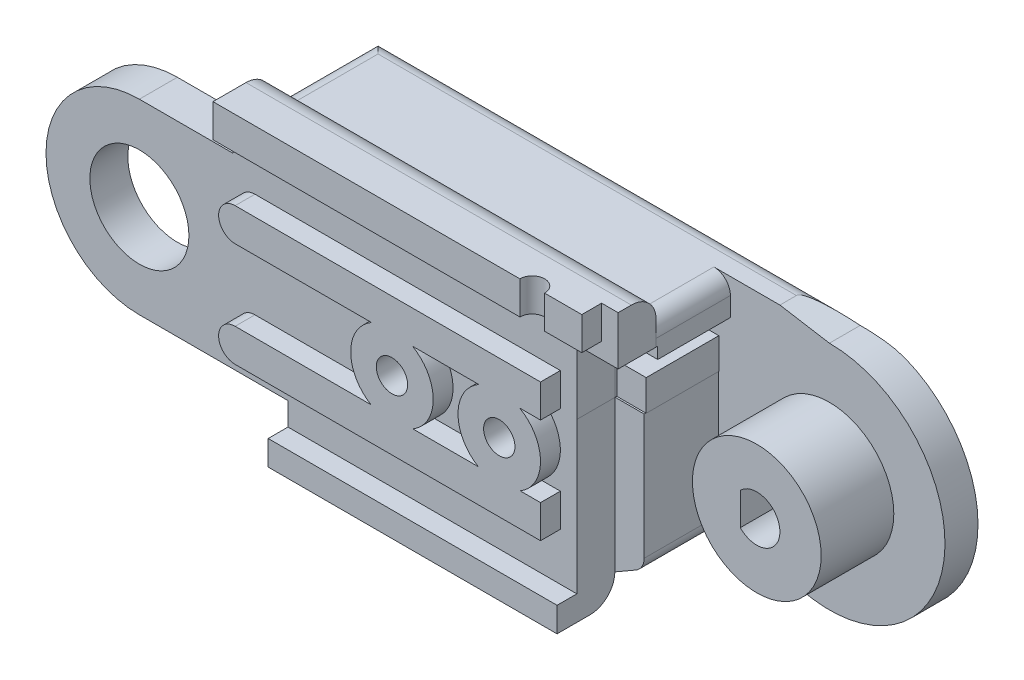
from build123d import *

# Parameters (mm, degrees)
BOSS_EXTRUDE1_DEPTH  = 2
BOSS_EXTRUDE6_DEPTH  = 4.5
CUT_EXTRUDE6_DEPTH   = 4.5
BOSS_EXTRUDE14_DEPTH = 2.3
SKETCH32_R           = 3
CUT_EXTRUDE7_DEPTH   = 2.3
SKETCH33_W           = 22.343119157
SKETCH33_H           = 2
SKETCH33_W_2         = 17.499973406
SKETCH33_H_2         = 1.5
BOSS_EXTRUDE15_DEPTH = 1.2
SKETCH35_W           = 5.479645996
SKETCH35_H           = 3.871139505
CUT_EXTRUDE8_DEPTH   = 2.4
SKETCH36_W           = 3.7
SKETCH36_H           = 1.871139505
CUT_EXTRUDE9_DEPTH   = 4.4
SKETCH37_R           = 3.9
BOSS_EXTRUDE16_DEPTH = 4.4
CUT_EXTRUDE10_DEPTH  = 7.4
SKETCH43_R           = 2.5
BOSS_EXTRUDE17_DEPTH = 1.2
SKETCH44_R           = 0.95
CUT_EXTRUDE11_DEPTH  = 11
SKETCH45_R           = 2
CUT_EXTRUDE12_DEPTH  = 4.5
SKETCH49_R           = 0.75
CUT_EXTRUDE13_DEPTH  = 3
SKETCH51_W           = 3
SKETCH51_H           = 3.965585241
CUT_EXTRUDE14_DEPTH  = 6.8
FILLET1_R            = 1.5
FILLET3_R            = 1


with BuildPart() as part:
    # Sketch3 → Boss-Extrude1 (new body)
    with BuildSketch(Plane.XY):
        with BuildLine():
            Line((8, 0), (9, -2.543145751))
            Line((9, -2.543145751), (9, -7.043145751))
            Line((9, -7.043145751), (26.499973406, -7.043145751))
            Line((26.499973406, -7.043145751), (30.050225938, -4.992893219))
            ThreePointArc((30.050225938, -4.992893219), (41.467130134, -2.721929777), (34.999973406, 6.956854249))
            Line((34.999973406, 6.956854249), (31.999973406, 7.456854249))
            Line((31.999973406, 7.456854249), (5.656854249, 7.456854249))
            Line((5.656854249, 7.456854249), (5.656854249, 5.656854249))
            ThreePointArc((5.656854249, 5.656854249), (7.39103626, 3.061467459), (8, 0))
        make_face()
    extrude(amount=BOSS_EXTRUDE1_DEPTH)

    # Sketch22 → Boss-Extrude6 (add)
    with BuildSketch(Plane.XY.offset(2)):
        with BuildLine():
            Line((5.656854249, 7.456854249), (26.499973406, 7.456854249))
            Line((26.499973406, 7.456854249), (31.999973406, 7.456854249))
            Line((31.999973406, 7.456854249), (31.999973406, 2.128860495))
            Line((31.999973406, 2.128860495), (28.275099672, 2.128860495))
            Line((28.275099672, 2.128860495), (28.275099672, -6.018019485))
            Line((28.275099672, -6.018019485), (26.499973406, -7.043145751))
            Line((26.499973406, -7.043145751), (9, -7.043145751))
            Line((9, -7.043145751), (9, -2.543145751))
            Line((9, -2.543145751), (8, 0))
            ThreePointArc((8, 0), (7.39103626, 3.061467459), (5.656854249, 5.656854249))
            Line((5.656854249, 5.656854249), (5.656854249, 7.456854249))
        make_face()
    extrude(amount=BOSS_EXTRUDE6_DEPTH)

    # Sketch26 → Cut-Extrude6 (cut)
    with BuildSketch(Plane.XY.offset(2)):
        Polygon((18.098080448, 5.3), (2.530052458, 5.3), (2.530052458, 4), (18.098080448, 4), (31.999973406, 4), (31.999973406, 5.3), align=None)
    extrude(amount=CUT_EXTRUDE6_DEPTH, mode=Mode.SUBTRACT)


with BuildPart() as body_2:
    # Sketch31 → Boss-Extrude14 (new body)
    with BuildSketch(Plane.XY.offset(6.5)):
        with BuildLine():
            Line((2.432688066, 5.656854249), (0, 5.656854249))
            ThreePointArc((0, 5.656854249), (-5.656854249, 0), (0, -5.656854249))
            Line((0, -5.656854249), (9, -5.656854249))
            Line((9, -5.656854249), (9, -7.043145751))
            Line((9, -7.043145751), (9, -8.543145751))
            Line((9, -8.543145751), (26.499973406, -8.543145751))
            Line((26.499973406, -8.543145751), (26.499973406, -7.043145751))
            Line((26.499973406, -7.043145751), (26.499973406, 2.128860495))
            Line((26.499973406, 2.128860495), (28.275099672, 2.128860495))
            Line((28.275099672, 2.128860495), (31.999973406, 2.128860495))
            Line((31.999973406, 2.128860495), (31.999973406, 7.456854249))
            Line((31.999973406, 7.456854249), (31.999973406, 8.956854249))
            Line((31.999973406, 8.956854249), (5.656854249, 8.956854249))
            Line((5.656854249, 8.956854249), (5.656854249, 7.456854249))
            Line((5.656854249, 7.456854249), (5.656854249, 5.656854249))
            Line((5.656854249, 5.656854249), (2.432688066, 5.656854249))
        make_face()
    extrude(amount=BOSS_EXTRUDE14_DEPTH)

    # Sketch32 → Cut-Extrude7 (cut)
    with BuildSketch(Plane.XY.offset(8.8)):
        Circle(SKETCH32_R)
    extrude(amount=-CUT_EXTRUDE7_DEPTH, mode=Mode.SUBTRACT)

    # Sketch33 → Boss-Extrude15 (add)
    with BuildSketch(Plane.XY.offset(8.8)):
        with Locations((16.828413828, 7.956854249)):
            Rectangle(SKETCH33_W, SKETCH33_H)
        with Locations((17.749986703, -7.793145751)):
            Rectangle(SKETCH33_W_2, SKETCH33_H_2)
        with BuildLine():
            Line((7, -4.156854249), (25.499973406, -4.156854249))
            Line((25.499973406, -4.156854249), (25.499973406, -2.156854249))
            Line((25.499973406, -2.156854249), (7, -2.156854249))
            ThreePointArc((7, -2.156854249), (6, -3.156854249), (7, -4.156854249))
        make_face()
        with BuildLine():
            Line((25.499973406, 2.172006245), (7, 2.172006245))
            ThreePointArc((7, 2.172006245), (6, 3.172006245), (7, 4.172006245))
            Line((7, 4.172006245), (25.499973406, 4.172006245))
            Line((25.499973406, 4.172006245), (25.499973406, 2.172006245))
        make_face()
    extrude(amount=BOSS_EXTRUDE15_DEPTH)


with BuildPart() as cut_extrude8_tool:
    # Sketch35 → Cut-Extrude8 (new body)
    with BuildSketch(Plane.XY.offset(8.8)):
        with Locations((29.260150408, 4.064430247)):
            Rectangle(SKETCH35_W, SKETCH35_H)
    extrude(amount=-CUT_EXTRUDE8_DEPTH)


with BuildPart() as part_1:
    add(part.part)

    # Cut-Extrude8: cut by cut_extrude8_tool
    add(cut_extrude8_tool.part, mode=Mode.SUBTRACT)

    # Sketch36 → Cut-Extrude9 (cut)
    with BuildSketch(Plane.XY.offset(6.4)):
        with Locations((30.149973406, 3.064430247)):
            Rectangle(SKETCH36_W, SKETCH36_H)
    extrude(amount=-CUT_EXTRUDE9_DEPTH, mode=Mode.SUBTRACT)

    # Sketch37 → Boss-Extrude16 (add)
    with BuildSketch(Plane.XY.offset(2)):
        with Locations((34.999973406, -0.043145751)):
            Circle(SKETCH37_R)
    extrude(amount=BOSS_EXTRUDE16_DEPTH)

    # Sketch39 → Cut-Extrude10 (cut, through all)
    with BuildSketch(Plane.XY.offset(6.4)):
        with BuildLine():
            Line((33.999973406, 0.936650147), (33.999973406, -1.022941648))
            ThreePointArc((33.999973406, -1.022941648), (36.399973406, -0.043145751), (33.999973406, 0.936650147))
        make_face()
    extrude(amount=-CUT_EXTRUDE10_DEPTH, mode=Mode.SUBTRACT)


with BuildPart() as body_2_1:
    add(body_2.part)

    # Cut-Extrude8: cut by cut_extrude8_tool
    add(cut_extrude8_tool.part, mode=Mode.SUBTRACT)

    # Sketch43 → Boss-Extrude17 (add)
    with BuildSketch(Plane.XY.offset(8.8)):
        with Locations((16.5, 0)):
            Circle(SKETCH43_R)
        with Locations((23, 0)):
            Circle(SKETCH43_R)
    extrude(amount=BOSS_EXTRUDE17_DEPTH)


with BuildPart() as cut_extrude11_tool:
    # Sketch44 → Cut-Extrude11 (new body, through all)
    with BuildSketch(Plane.XY.offset(10)):
        with Locations((16.5, 0)):
            Circle(SKETCH44_R)
        with Locations((23, 0)):
            Circle(SKETCH44_R)
    extrude(amount=-CUT_EXTRUDE11_DEPTH)


with BuildPart() as part_2:
    add(part_1.part)

    # Cut-Extrude11: cut by cut_extrude11_tool
    add(cut_extrude11_tool.part, mode=Mode.SUBTRACT)

    # Sketch45 → Cut-Extrude12 (cut)
    with BuildSketch(Plane(origin=(0, 0, 0), x_dir=(-1, 0, 0), z_dir=(0, 0, -1))):
        with Locations((-16.5, 0)):
            Circle(SKETCH45_R)
        with Locations((-23, 0)):
            Circle(SKETCH45_R)
    extrude(amount=-CUT_EXTRUDE12_DEPTH, mode=Mode.SUBTRACT)


with BuildPart() as body_2_2:
    add(body_2_1.part)

    # Cut-Extrude11: cut by cut_extrude11_tool
    add(cut_extrude11_tool.part, mode=Mode.SUBTRACT)

    # Sketch49 → Cut-Extrude13 (cut)
    with BuildSketch(Plane.XZ.offset(-6.956854249)):
        with Locations((24.999973406, 10)):
            Circle(SKETCH49_R)
    extrude(amount=-CUT_EXTRUDE13_DEPTH, mode=Mode.SUBTRACT)


with BuildPart() as cut_extrude14_tool:
    # Sketch51 → Cut-Extrude14 (new body)
    with BuildSketch(Plane.XY.offset(8.8)):
        with Locations((30.499973406, 6.974061629)):
            Rectangle(SKETCH51_W, SKETCH51_H)
    extrude(amount=-CUT_EXTRUDE14_DEPTH)


with BuildPart() as part_3:
    add(part_2.part)

    # Cut-Extrude14: cut by cut_extrude14_tool
    add(cut_extrude14_tool.part, mode=Mode.SUBTRACT)

    # Fillet3
    fillet3_edges = [part_3.edges().sort_by_distance(p)[0] for p in [
        (28.275099672, -6.018019485, 4.25),
        (28.999973406, 7.456854249, 4.25),
        (9, -7.043145751, 3.25),
        (5.656854249, 7.456854249, 3.25),
        (17.749986703, -7.043145751, 0),
        (18.828413828, 7.456854249, 0),
    ]]
    fillet(fillet3_edges, radius=FILLET3_R)


with BuildPart() as body_2_3:
    add(body_2_2.part)

    # Cut-Extrude14: cut by cut_extrude14_tool
    add(cut_extrude14_tool.part, mode=Mode.SUBTRACT)

    # Fillet1
    fillet1_edges = [body_2_3.edges().sort_by_distance(p)[0] for p in [
        (17.328413828, 8.956854249, 6.5),
        (17.749986703, -8.543145751, 6.5),
    ]]
    fillet(fillet1_edges, radius=FILLET1_R)


solid = Compound([part_3.part, body_2_3.part])
